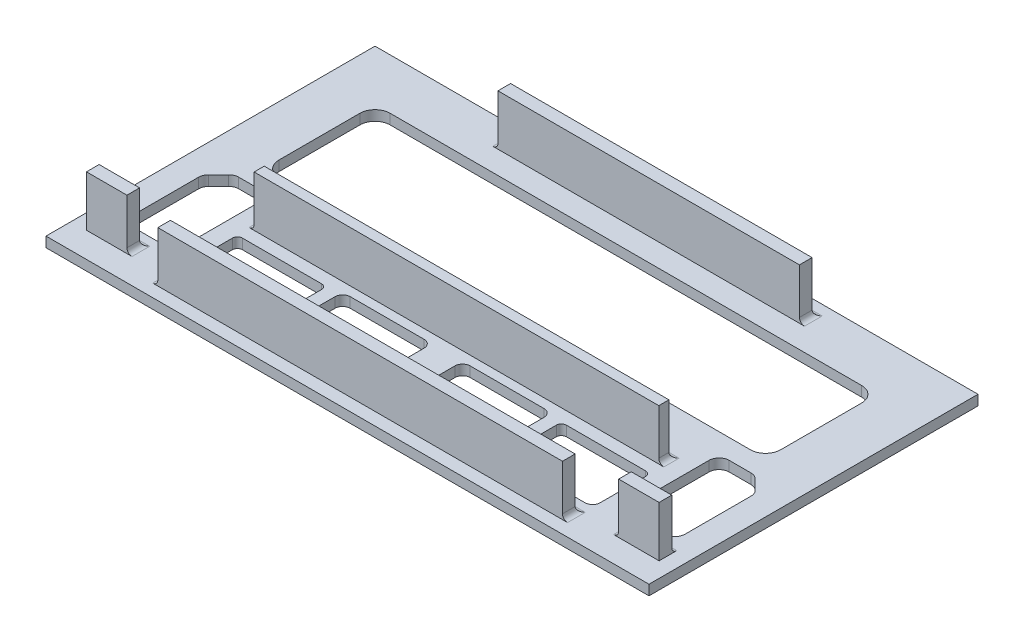
from build123d import *

# Parameters (mm, degrees)
SKETCH1_W           = 119.2
SKETCH1_H           = 65.04
BOSS_EXTRUDE1_DEPTH = 2
SKETCH2_W           = 59.6
SKETCH2_H           = 2.5
SKETCH2_W_2         = 80
SKETCH2_H_2         = 2
BOSS_EXTRUDE2_DEPTH = 10
FILLET1_R           = 1
SKETCH4_W           = 80
SKETCH4_H           = 2.5
SKETCH4_W_2         = 8
BOSS_EXTRUDE3_DEPTH = 10
FILLET2_R           = 1
FILLET3_R           = 1
CUT_EXTRUDE2_DEPTH  = 10
CUT_EXTRUDE3_DEPTH  = 10


with BuildPart() as part:
    # Sketch1 → Boss-Extrude1 (new body)
    with BuildSketch(Plane(origin=(0, 0, 0), x_dir=(1, 0, 0), z_dir=(0, 1, 0))):
        Rectangle(SKETCH1_W, SKETCH1_H)
    extrude(amount=BOSS_EXTRUDE1_DEPTH)

    # Sketch2 → Boss-Extrude2 (add)
    with BuildSketch(Plane(origin=(0, 2, 0), x_dir=(1, 0, 0), z_dir=(0, 1, 0))):
        with Locations((0, 28.27)):
            Rectangle(SKETCH2_W, SKETCH2_H)
        with Locations((0, -9.98)):
            Rectangle(SKETCH2_W_2, SKETCH2_H_2)
    extrude(amount=BOSS_EXTRUDE2_DEPTH)

    # Fillet1
    fillet1_edges = [part.edges().sort_by_distance(p)[0] for p in [
        (-29.8, 2, -28.27),
        (29.8, 2, -28.27),
        (0, 2, -29.52),
        (-40, 2, 9.98),
        (40, 2, 9.98),
        (0, 2, 8.98),
    ]]
    fillet(fillet1_edges, radius=FILLET1_R)

    # Sketch4 → Boss-Extrude3 (add)
    with BuildSketch(Plane(origin=(0, 2, 0), x_dir=(1, 0, 0), z_dir=(0, 1, 0))):
        with Locations((0, -28.77)):
            Rectangle(SKETCH4_W, SKETCH4_H)
        with Locations((52.6, -26.27)):
            Rectangle(SKETCH4_W_2, SKETCH4_H)
    boss_extrude3 = extrude(amount=BOSS_EXTRUDE3_DEPTH)

    # Fillet2
    fillet2_edges = [part.edges().sort_by_distance(p)[0] for p in [
        (-40, 2, 28.77),
        (48.6, 2, 26.27),
        (52.6, 2, 25.02),
        (40, 2, 28.77),
        (0, 2, 27.52),
    ]]
    fillet(fillet2_edges, radius=FILLET2_R)

    # Mirror1: Boss-Extrude3 across plane
    add(boss_extrude3.mirror(Plane.ZY))

    # Fillet3
    fillet3_edges = [part.edges().sort_by_distance(p)[0] for p in [
        (-52.6, 2, 25.02),
        (-48.6, 2, 26.27),
    ]]
    fillet(fillet3_edges, radius=FILLET3_R)

    # Sketch5 → Cut-Extrude2 (cut)
    with BuildSketch(Plane(origin=(0, 2, 0), x_dir=(1, 0, 0), z_dir=(0, 1, 0))):
        with BuildLine():
            Line((46.6, 22.52), (6.311514948, 22.52))
            Line((6.311514948, 22.52), (-46.6, 22.52))
            ThreePointArc((-46.6, 22.52), (-48.721320344, 21.641320344), (-49.6, 19.52))
            Line((-49.6, 19.52), (-49.6, 3.52))
            ThreePointArc((-49.6, 3.52), (-48.721320344, 1.398679656), (-46.6, 0.52))
            Line((-46.6, 0.52), (46.6, 0.52))
            ThreePointArc((46.6, 0.52), (48.721320344, 1.398679656), (49.6, 3.52))
            Line((49.6, 3.52), (49.6, 19.52))
            ThreePointArc((49.6, 19.52), (48.721320344, 21.641320344), (46.6, 22.52))
        make_face()
    extrude(amount=-CUT_EXTRUDE2_DEPTH, mode=Mode.SUBTRACT)

    # Sketch6 → Cut-Extrude3 (cut)
    with BuildSketch(Plane(origin=(0, 2, 0), x_dir=(1, 0, 0), z_dir=(0, 1, 0))):
        with BuildLine():
            Line((54.014213562, -5.94084617), (52.045315698, -3.971948306))
            ThreePointArc((52.045315698, -3.971948306), (51.396469, -3.538402803), (50.631102135, -3.386161868))
            Line((50.631102135, -3.386161868), (46.32782558, -3.386161868))
            ThreePointArc((46.32782558, -3.386161868), (44.913612017, -3.971948306), (44.32782558, -5.386161868))
            Line((44.32782558, -5.386161868), (44.32782558, -20.397912268))
            ThreePointArc((44.32782558, -20.397912268), (44.913612017, -21.812125831), (46.32782558, -22.397912268))
            Line((46.32782558, -22.397912268), (52.6, -22.397912268))
            ThreePointArc((52.6, -22.397912268), (54.014213562, -21.812125831), (54.6, -20.397912268))
            Line((54.6, -20.397912268), (54.6, -7.355059733))
            ThreePointArc((54.6, -7.355059733), (54.447759065, -6.589692868), (54.014213562, -5.94084617))
        make_face()
        with BuildLine():
            Line((39.82782558, -13.44932419), (24.210760832, -13.44932419))
            ThreePointArc((24.210760832, -13.44932419), (23.503654051, -13.742217409), (23.210760832, -14.44932419))
            Line((23.210760832, -14.44932419), (23.210760832, -23.393622011))
            ThreePointArc((23.210760832, -23.393622011), (23.650100661, -24.454282183), (24.710760832, -24.893622011))
            Line((24.710760832, -24.893622011), (39.32782558, -24.893622011))
            ThreePointArc((39.32782558, -24.893622011), (40.388485752, -24.454282183), (40.82782558, -23.393622011))
            Line((40.82782558, -23.393622011), (40.82782558, -14.44932419))
            ThreePointArc((40.82782558, -14.44932419), (40.534932361, -13.742217409), (39.82782558, -13.44932419))
        make_face()
        with BuildLine():
            Line((4.043952302, -24.893622011), (19.660852384, -24.893622011))
            ThreePointArc((19.660852384, -24.893622011), (20.367959165, -24.600728792), (20.660852384, -23.893622011))
            Line((20.660852384, -23.893622011), (20.660852384, -14.321364431))
            ThreePointArc((20.660852384, -14.321364431), (20.221512556, -13.260704259), (19.160852384, -12.821364431))
            Line((19.160852384, -12.821364431), (4.543952302, -12.821364431))
            ThreePointArc((4.543952302, -12.821364431), (3.48329213, -13.260704259), (3.043952302, -14.321364431))
            Line((3.043952302, -14.321364431), (3.043952302, -23.893622011))
            ThreePointArc((3.043952302, -23.893622011), (3.336845521, -24.600728792), (4.043952302, -24.893622011))
        make_face()
        with BuildLine():
            Line((-4.043952302, -24.893622011), (-19.660852384, -24.893622011))
            ThreePointArc((-19.660852384, -24.893622011), (-20.367959165, -24.600728792), (-20.660852384, -23.893622011))
            Line((-20.660852384, -23.893622011), (-20.660852384, -14.321364431))
            ThreePointArc((-20.660852384, -14.321364431), (-20.221512556, -13.260704259), (-19.160852384, -12.821364431))
            Line((-19.160852384, -12.821364431), (-4.543952302, -12.821364431))
            ThreePointArc((-4.543952302, -12.821364431), (-3.48329213, -13.260704259), (-3.043952302, -14.321364431))
            Line((-3.043952302, -14.321364431), (-3.043952302, -23.893622011))
            ThreePointArc((-3.043952302, -23.893622011), (-3.336845521, -24.600728792), (-4.043952302, -24.893622011))
        make_face()
        with BuildLine():
            Line((-39.32782558, -24.893622011), (-24.710760832, -24.893622011))
            ThreePointArc((-24.710760832, -24.893622011), (-23.650100661, -24.454282183), (-23.210760832, -23.393622011))
            Line((-23.210760832, -23.393622011), (-23.210760832, -14.44932419))
            ThreePointArc((-23.210760832, -14.44932419), (-23.503654051, -13.742217409), (-24.210760832, -13.44932419))
            Line((-24.210760832, -13.44932419), (-39.82782558, -13.44932419))
            ThreePointArc((-39.82782558, -13.44932419), (-40.534932361, -13.742217409), (-40.82782558, -14.44932419))
            Line((-40.82782558, -14.44932419), (-40.82782558, -23.393622011))
            ThreePointArc((-40.82782558, -23.393622011), (-40.388485752, -24.454282183), (-39.32782558, -24.893622011))
        make_face()
        with BuildLine():
            Line((-44.32782558, -5.386161868), (-44.32782558, -20.397912268))
            ThreePointArc((-44.32782558, -20.397912268), (-44.913612017, -21.812125831), (-46.32782558, -22.397912268))
            Line((-46.32782558, -22.397912268), (-52.6, -22.397912268))
            ThreePointArc((-52.6, -22.397912268), (-54.014213562, -21.812125831), (-54.6, -20.397912268))
            Line((-54.6, -20.397912268), (-54.6, -7.355059733))
            ThreePointArc((-54.6, -7.355059733), (-54.447759065, -6.589692868), (-54.014213562, -5.94084617))
            Line((-54.014213562, -5.94084617), (-52.045315698, -3.971948306))
            ThreePointArc((-52.045315698, -3.971948306), (-51.396469, -3.538402803), (-50.631102135, -3.386161868))
            Line((-50.631102135, -3.386161868), (-46.32782558, -3.386161868))
            ThreePointArc((-46.32782558, -3.386161868), (-44.913612017, -3.971948306), (-44.32782558, -5.386161868))
        make_face()
    extrude(amount=-CUT_EXTRUDE3_DEPTH, mode=Mode.SUBTRACT)


solid = part.part
